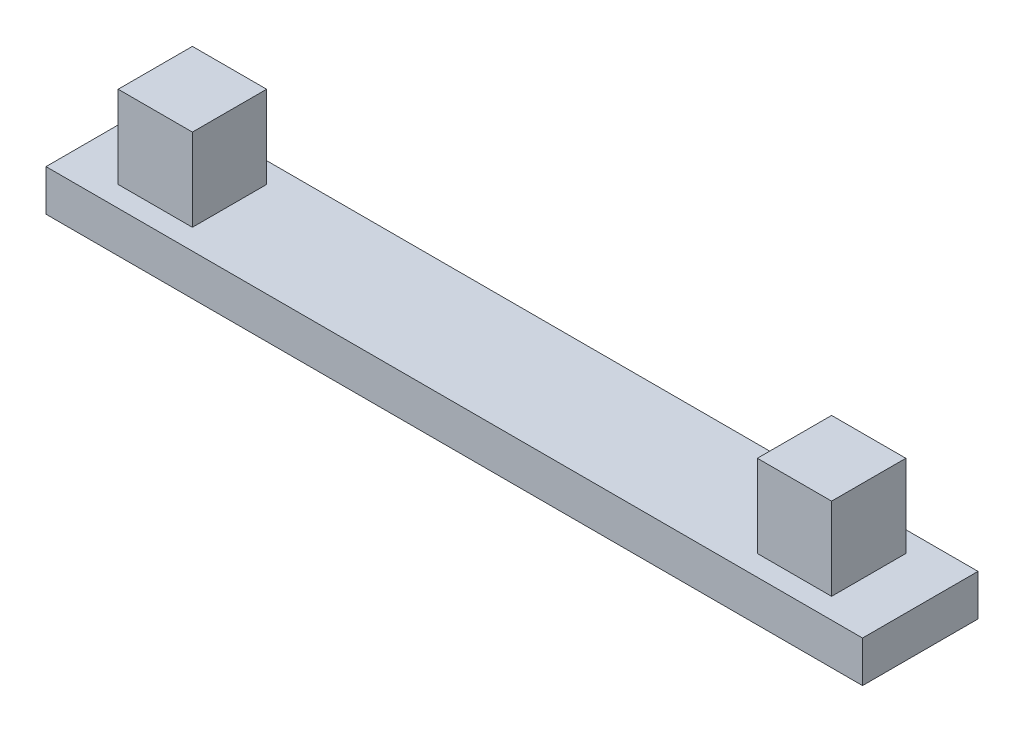
from build123d import *

# Parameters (mm, degrees)
SKETCH1_W           = 19.8
SKETCH1_H           = 2.8
SKETCH1_W_2         = 1.8
SKETCH1_H_2         = 1.8
BOSS_EXTRUDE1_DEPTH = 1
SKETCH1_3_W         = 1.8
SKETCH1_3_H         = 1.8
BOSS_EXTRUDE2_DEPTH = 3


with BuildPart() as part:
    # Sketch1 → Boss-Extrude1 (new body)
    with BuildSketch(Plane(origin=(0, 0, 0), x_dir=(1, 0, 0), z_dir=(0, 1, 0))):
        with Locations((9.9, 1.4)):
            Rectangle(SKETCH1_W, SKETCH1_H)
        with Locations((17.65, 1.4)):
            Rectangle(SKETCH1_W_2, SKETCH1_H_2, mode=Mode.SUBTRACT)
        with Locations((2.15, 1.4)):
            Rectangle(SKETCH1_W_2, SKETCH1_H_2, mode=Mode.SUBTRACT)
    extrude(amount=BOSS_EXTRUDE1_DEPTH)

    # Sketch1_3 → Boss-Extrude2 (add)
    with BuildSketch(Plane(origin=(0, 0, 0), x_dir=(1, 0, 0), z_dir=(0, 1, 0))):
        with Locations((2.15, 1.4)):
            Rectangle(SKETCH1_3_W, SKETCH1_3_H)
        with Locations((17.65, 1.4)):
            Rectangle(SKETCH1_3_W, SKETCH1_3_H)
    extrude(amount=BOSS_EXTRUDE2_DEPTH)


solid = part.part
